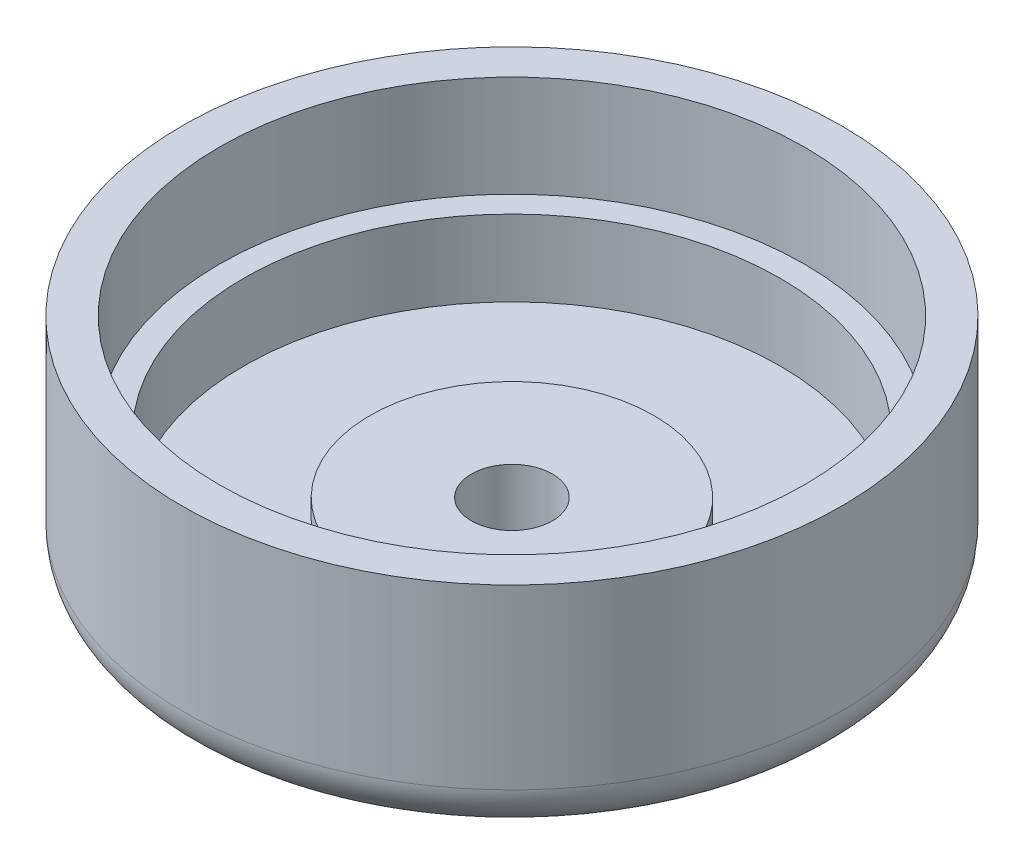
from build123d import *

# Parameters (mm, degrees)
FILLET1_R = 4.5


with BuildPart() as part:
    # Sketch2 → Revolve1 (revolve)
    with BuildSketch(Plane.XY):
        Polygon((4, 0), (28.52273273, 0), (32.5, 0), (32.5, 10), (32.5, 22), (28.85, 22), (28.85, 12), (26.45, 12), (26.45, 4.5), (14, 4.5), (14, 6.5), (4, 6.5), (4, 4), align=None)
    revolve(axis=Axis((0, 0, 0), (0, 1, 0)))

    # Fillet1
    fillet1_edges = [part.edges().sort_by_distance(p)[0] for p in [
        (-32.5, 0, 0),
    ]]
    fillet(fillet1_edges, radius=FILLET1_R)


solid = part.part
